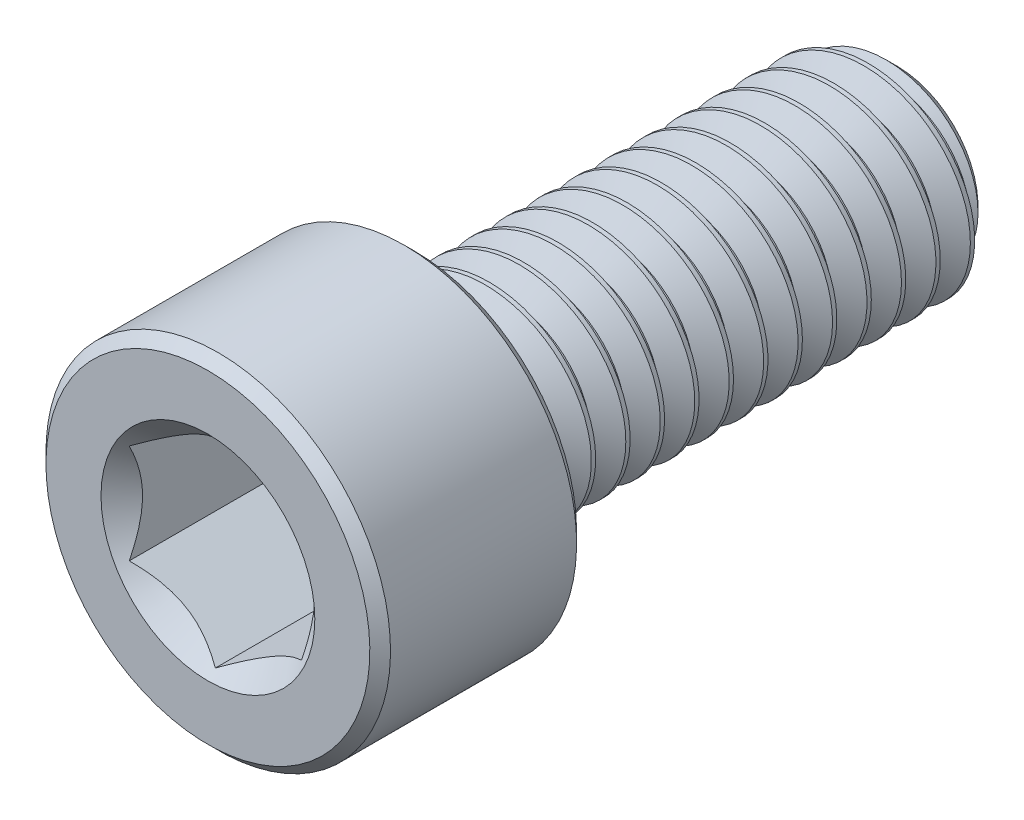
from build123d import *

# Parameters (mm, degrees)
CUT_EXTRUDE1_DEPTH     = 5
SKETCH4_R              = 3.103257696894239
CUT_EXTRUDE2_DEPTH     = 3
CUT_EXTRUDE2_DRAFT     = -45.0000000000001
SPLIT1_SURFACE_1_BACK  = 25.495
SPLIT1_SURFACE_1_DEPTH = 50.99
SPLIT1_SURFACE_2_BACK  = 25.495
SPLIT1_SURFACE_2_DEPTH = 50.99
CUT_SWEEP1_PITCH       = 1.0000000000000013
CUT_SWEEP1_HEIGHT      = 15.000000000000012
CUT_SWEEP1_RADIUS      = 3.0000000000000004
CUT_SWEEP1_START_ANGLE = 89.9999999999998


with BuildPart() as part:
    # Sketch2 → Revolve1 (revolve)
    with BuildSketch(Plane(origin=(0, 0, 0), x_dir=(0, 0, -1), z_dir=(1, 0, 0))):
        with BuildLine():
            Line((-10, 0), (-10, 4.7))
            Line((-10, 4.7), (-9.700000000000001, 5))
            Line((-9.700000000000001, 5), (-4.3, 5))
            Line((-4.3, 5), (-4, 4.7))
            Line((-4, 4.7), (-3.999999999999999, 3.3000000000000003))
            ThreePointArc((-3.999999999999999, 3.3000000000000003), (-3.9121320343559636, 3.087867965644037), (-3.7, 3.0000000000000004))
            Line((-3.7, 3.0000000000000004), (9.350480947161667, 3))
            Line((9.350480947161667, 3), (10, 2.3504809471616706))
            Line((10, 2.3504809471616706), (10, 0))
            Line((10, 0), (-10, 0))
        make_face()
    revolve(axis=Axis((0, 0, -10), (0, 0, 1)))

    # Sketch3 → Cut-Extrude1 (cut)
    with BuildSketch(Plane.XY.offset(10)):
        Polygon((2.5, -1.4433756729740648), (2.5, 1.4433756729740643), (-8.6e-16, 2.8867513459481287), (-2.5, 1.4433756729740637), (-2.5, -1.4433756729740652), (8.7e-16, -2.8867513459481304), align=None)
    extrude(amount=-CUT_EXTRUDE1_DEPTH, mode=Mode.SUBTRACT)


with BuildPart() as cut_extrude2_tool:
    # Sketch4 → Cut-Extrude2 (with draft: the straight prism first)
    with BuildSketch(Plane.XY.offset(10)):
        Circle(SKETCH4_R)
    extrude(amount=-CUT_EXTRUDE2_DEPTH)
    # Cut-Extrude2: the draft: its side faces are tilted about the plane it starts from
    cut_extrude2_sides = [cut_extrude2_tool.faces().sort_by_distance(p)[0] for p in [
        (-3.103257697, 0, 8.5),
    ]]
    draft(cut_extrude2_sides, Plane.XY.offset(10), CUT_EXTRUDE2_DRAFT)


with BuildPart() as part_1:
    add(part.part)

    # Cut-Extrude2: cut by cut_extrude2_tool
    add(cut_extrude2_tool.part, mode=Mode.SUBTRACT)


with BuildPart() as body_2:
    # Split1: the piece behind the surface
    add(part_1.part)
    # Split1 surface: a surface, the sketch's curves swept straight by 50.99 mm
    with BuildLine(Plane(origin=(0, 0, 0), x_dir=(0, 0, -1), z_dir=(1, 0, 0)).offset(-SPLIT1_SURFACE_1_BACK), mode=Mode.PRIVATE) as split1_surface_1_path:
        Line((-3.7, -5), (-3.7, 5))
    split1_surface_1 = Shell.extrude(split1_surface_1_path.wire(), (1 * SPLIT1_SURFACE_1_DEPTH, 0 * SPLIT1_SURFACE_1_DEPTH, 0 * SPLIT1_SURFACE_1_DEPTH))
    split(bisect_by=split1_surface_1, keep=Keep.BOTTOM)

    # Cut-Sweep1: sweep along a helix
    with BuildLine() as cut_sweep1_path:
        add(Helix(CUT_SWEEP1_PITCH, CUT_SWEEP1_HEIGHT, CUT_SWEEP1_RADIUS, center=(0, 0, -10), direction=(0, 0, 1), mode=Mode.PRIVATE).rotate(Axis((0, 0, -10), (0, 0, 1)), CUT_SWEEP1_START_ANGLE))
    # Sketch7 → Cut-Sweep1 (sweep, cut)
    with BuildSketch(Plane(origin=(0, 0, 0), x_dir=(0, 0, -1), z_dir=(1, 0, 0))):
        Polygon((9.968749999999998, 3.0541265877365276), (10.90625, 3.0541265877365276), (10.499999999999998, 2.3504809471616706), (10.374999999999998, 2.3504809471616706), align=None)
    sweep(path=cut_sweep1_path.line, is_frenet=True, mode=Mode.SUBTRACT)


with BuildPart() as part_2:
    add(part_1.part)

    # Split1: split by a surface, the side it looks to stays
    # Split1 surface: a surface, the sketch's curves swept straight by 50.99 mm
    with BuildLine(Plane(origin=(0, 0, 0), x_dir=(0, 0, -1), z_dir=(1, 0, 0)).offset(-SPLIT1_SURFACE_2_BACK), mode=Mode.PRIVATE) as split1_surface_2_path:
        Line((-3.7, -5), (-3.7, 5))
    split1_surface_2 = Shell.extrude(split1_surface_2_path.wire(), (1 * SPLIT1_SURFACE_2_DEPTH, 0 * SPLIT1_SURFACE_2_DEPTH, 0 * SPLIT1_SURFACE_2_DEPTH))
    split(bisect_by=split1_surface_2, keep=Keep.TOP)

    add(body_2.part)  # Revolve2 merges body 2
    # Sketch8 → Revolve2 (revolve)
    with BuildSketch(Plane(origin=(0, 0, 0), x_dir=(0, 0, -1), z_dir=(1, 0, 0))):
        Polygon((-4, 4.1e-16), (-4, 3), (-3.7, 3.0000000000000004), (-1.9679491924311032, 5.6e-16), align=None)
    revolve(axis=Axis((0, 5.6e-16, 1.9679491924311032), (0, -7e-17, 1)))


solid = part_2.part
